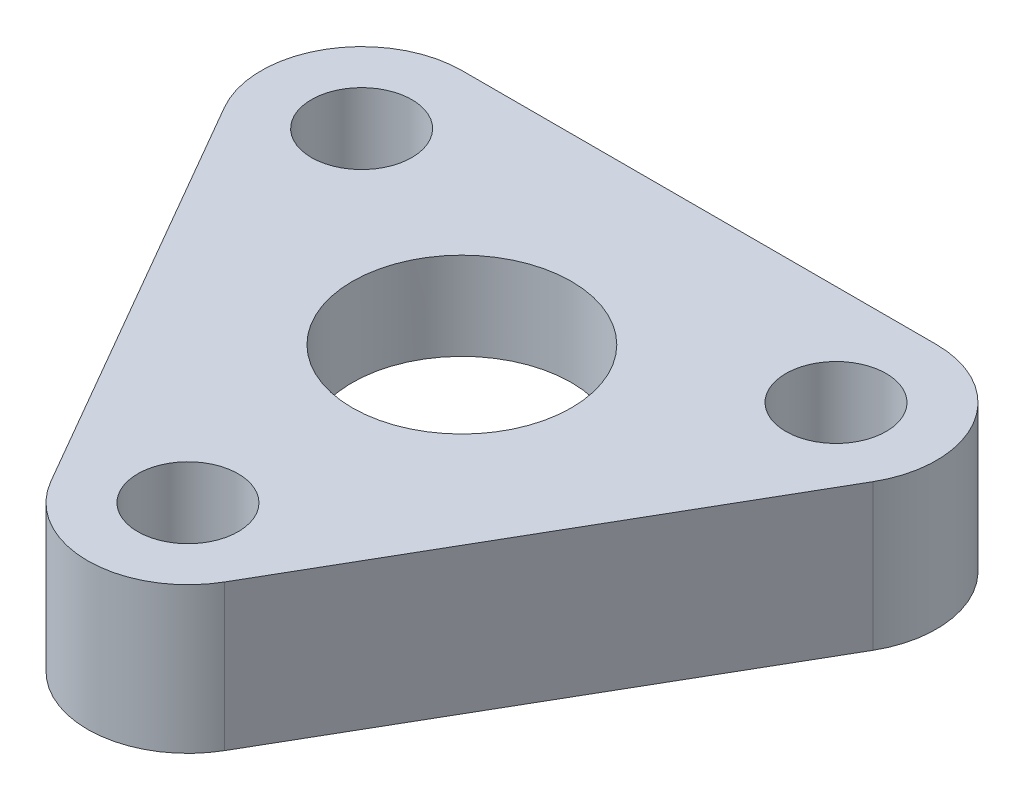
from build123d import *

# Parameters (mm, degrees)
SKETCH1_R           = 6
SKETCH1_R_2         = 2.75
BOSS_EXTRUDE1_DEPTH = 8
SKETCH2_R           = 11.25
CUT_EXTRUDE1_DEPTH  = 3.2


with BuildPart() as part:
    # Sketch1 → Boss-Extrude1 (new body)
    with BuildSketch(Plane(origin=(0, 0, 0), x_dir=(1, 0, 0), z_dir=(0, 1, 0))):
        with BuildLine():
            Line((-12.990381057, 13), (12.990381057, 13))
            ThreePointArc((12.990381057, 13), (17.753520778, 10.25), (17.753520778, 4.75))
            Line((17.753520778, 4.75), (4.763139721, -17.75))
            ThreePointArc((4.763139721, -17.75), (0, -20.5), (-4.763139721, -17.75))
            Line((-4.763139721, -17.75), (-17.753520778, 4.75))
            ThreePointArc((-17.753520778, 4.75), (-17.753520778, 10.25), (-12.990381057, 13))
        make_face()
        Circle(SKETCH1_R, mode=Mode.SUBTRACT)
        with Locations((-12.990381057, 7.5)):
            Circle(SKETCH1_R_2, mode=Mode.SUBTRACT)
        with Locations((12.990381057, 7.5)):
            Circle(SKETCH1_R_2, mode=Mode.SUBTRACT)
        with Locations((0, -15)):
            Circle(SKETCH1_R_2, mode=Mode.SUBTRACT)
    extrude(amount=BOSS_EXTRUDE1_DEPTH)

    # Sketch2 → Cut-Extrude1 (cut)
    with BuildSketch(Plane.XZ):
        Circle(SKETCH2_R)
    extrude(amount=-CUT_EXTRUDE1_DEPTH, mode=Mode.SUBTRACT)


solid = part.part
